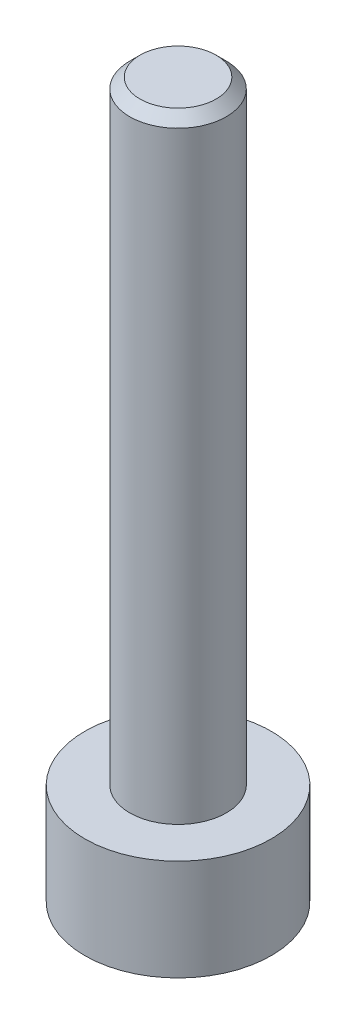
from build123d import *

# Parameters (mm, degrees)
SKETCH1_R           = 1.825
BOSS_EXTRUDE1_DEPTH = 1.98
SKETCH2_R           = 0.945
BOSS_EXTRUDE2_DEPTH = 12
CUT_EXTRUDE1_DEPTH  = 1
CHAMFER1_SIZE       = 0.2


with BuildPart() as part:
    # Sketch1 → Boss-Extrude1 (new body)
    with BuildSketch(Plane(origin=(0, 0, 0), x_dir=(1, 0, 0), z_dir=(0, 1, 0))):
        Circle(SKETCH1_R)
    extrude(amount=BOSS_EXTRUDE1_DEPTH)

    # Sketch2 → Boss-Extrude2 (add)
    with BuildSketch(Plane(origin=(0, 1.98, 0), x_dir=(1, 0, 0), z_dir=(0, 1, 0))):
        Circle(SKETCH2_R)
    extrude(amount=BOSS_EXTRUDE2_DEPTH)

    # Sketch3 → Cut-Extrude1 (cut)
    with BuildSketch(Plane.XZ):
        Polygon((0.458993464, -0.795), (0.917986928, 0), (0.458993464, 0.795), (-0.458993464, 0.795), (-0.917986928, 0), (-0.458993464, -0.795), align=None)
    extrude(amount=-CUT_EXTRUDE1_DEPTH, mode=Mode.SUBTRACT)

    # Chamfer1
    chamfer1_edges = [part.edges().sort_by_distance(p)[0] for p in [
        (-0.945, 13.98, 0),
    ]]
    chamfer(chamfer1_edges, length=CHAMFER1_SIZE)


solid = part.part
